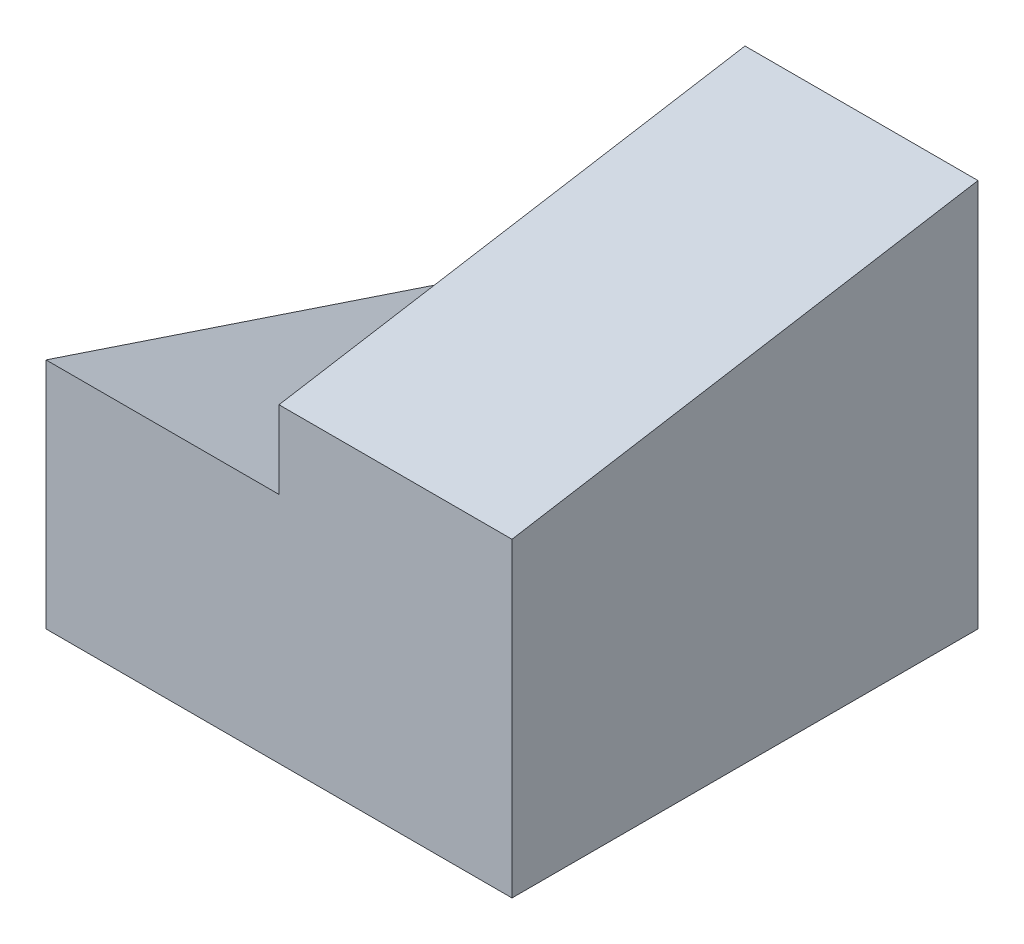
from build123d import *

# Parameters (mm, degrees)
SKETCH3_W           = 6
SKETCH3_H           = 5
BOSS_EXTRUDE6_DEPTH = 6
CUT_EXTRUDE4_DEPTH  = 6
CUT_EXTRUDE5_DEPTH  = 3


with BuildPart() as part:
    # Sketch3 → Boss-Extrude6 (new body)
    with BuildSketch(Plane.XY):
        with Locations((3, 2.5)):
            Rectangle(SKETCH3_W, SKETCH3_H)
    extrude(amount=BOSS_EXTRUDE6_DEPTH)

    # Sketch7 → Cut-Extrude4 (cut)
    with BuildSketch(Plane.ZY):
        Polygon((0, 5), (6, 4), (6, 5), align=None)
    extrude(amount=-CUT_EXTRUDE4_DEPTH, mode=Mode.SUBTRACT)

    # Sketch8 → Cut-Extrude5 (cut)
    with BuildSketch(Plane.ZY):
        Polygon((0, 5), (6, 4), (6, 3), (0, 1), align=None)
    extrude(amount=-CUT_EXTRUDE5_DEPTH, mode=Mode.SUBTRACT)


solid = part.part
